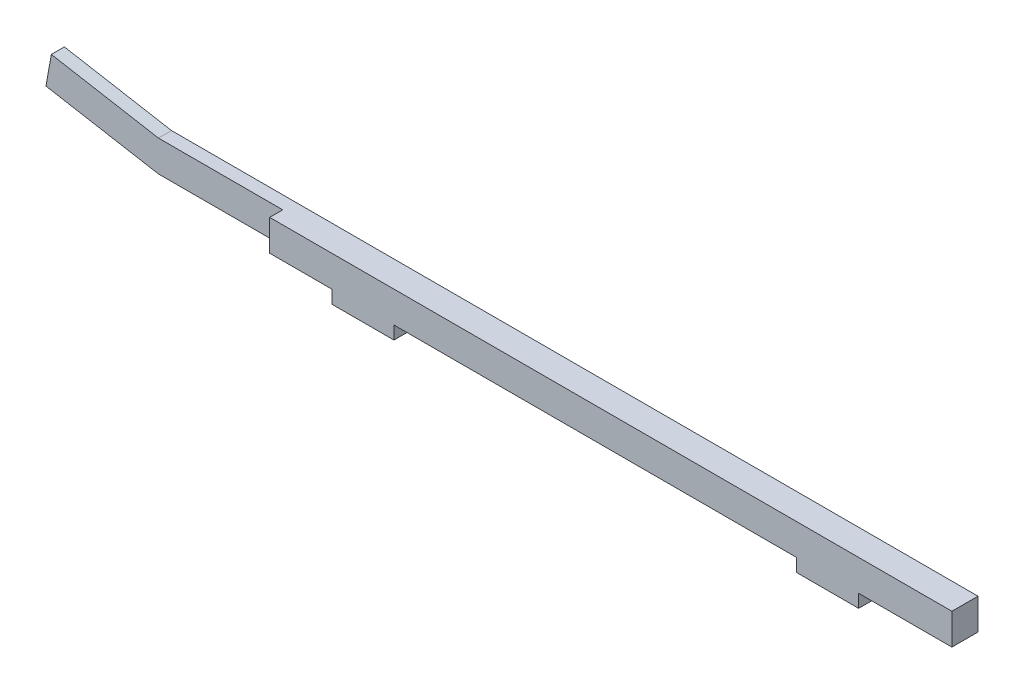
from build123d import *

# Parameters (mm, degrees)
SKETCH1_W             = 25.4
SKETCH1_H             = 10.668
BOSS_EXTRUDE1_DEPTH   = 5.334
BOSS_EXTRUDE1_2_DEPTH = 5.334
SKETCH1_3_W           = 329.617035208
SKETCH1_3_H           = 10.668
BOSS_EXTRUDE2_DEPTH   = 12.7
DIHEDRAL_ANGLE_DEPTH  = 5.334
SKETCH3_W             = 50.8
SKETCH3_H             = 12.7
CUT_EXTRUDE1_DEPTH    = 5.334


with BuildPart() as part:
    # Sketch1 → Boss-Extrude1 (new body)
    with BuildSketch(Plane(origin=(0, 5.334, 0), x_dir=(1, 0, 0), z_dir=(0, 1, 0))):
        with Locations((278.817035208, -59.945526857)):
            Rectangle(SKETCH1_W, SKETCH1_H)
    extrude(amount=-BOSS_EXTRUDE1_DEPTH)



with BuildPart() as body_2:
    # Sketch1 → Boss-Extrude1 2 (new body)
    with BuildSketch(Plane(origin=(0, 5.334, 0), x_dir=(1, 0, 0), z_dir=(0, 1, 0))):
        with Locations((88.9, -59.945526857)):
            Rectangle(SKETCH1_W, SKETCH1_H)
    extrude(amount=-BOSS_EXTRUDE1_2_DEPTH)


with BuildPart() as part_1:
    add(part.part)

    add(body_2.part)  # Boss-Extrude2 merges body 2
    # Sketch1_3 → Boss-Extrude2 (add)
    with BuildSketch(Plane(origin=(0, 5.334, 0), x_dir=(1, 0, 0), z_dir=(0, 1, 0))):
        with Locations((164.808517604, -59.945526857)):
            Rectangle(SKETCH1_3_W, SKETCH1_3_H)
    extrude(amount=BOSS_EXTRUDE2_DEPTH)

    # Sketch2 → Dihedral Angle (add)
    with BuildSketch(Plane(origin=(0, 0, 54.611526857), x_dir=(-1, 0, 0), z_dir=(0, 0, -1))):
        Polygon((0, 5.334), (45.946532532, 13.435613355), (43.774704621, 25.752661497), (0, 18.034), align=None)
    extrude(amount=-DIHEDRAL_ANGLE_DEPTH)

    # Sketch3 → Cut-Extrude1 (cut)
    with BuildSketch(Plane.XY.offset(65.279526857)):
        with Locations((25.4, 11.684)):
            Rectangle(SKETCH3_W, SKETCH3_H)
    extrude(amount=-CUT_EXTRUDE1_DEPTH, mode=Mode.SUBTRACT)


solid = part_1.part
